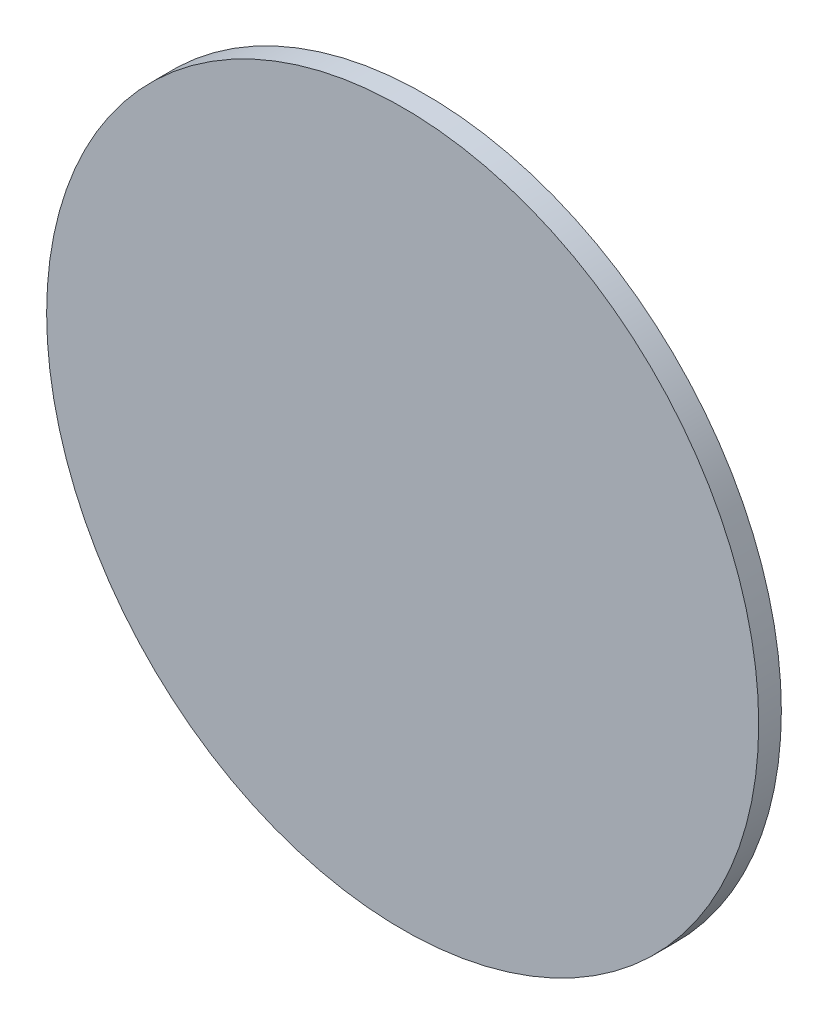
from build123d import *

# Parameters (mm, degrees)
SKETCH1_R           = 24.9555
BOSS_EXTRUDE1_DEPTH = 1.5875


with BuildPart() as part:
    # Sketch1 → Boss-Extrude1 (new body)
    with BuildSketch(Plane.XY):
        Circle(SKETCH1_R)
    extrude(amount=BOSS_EXTRUDE1_DEPTH)


solid = part.part
